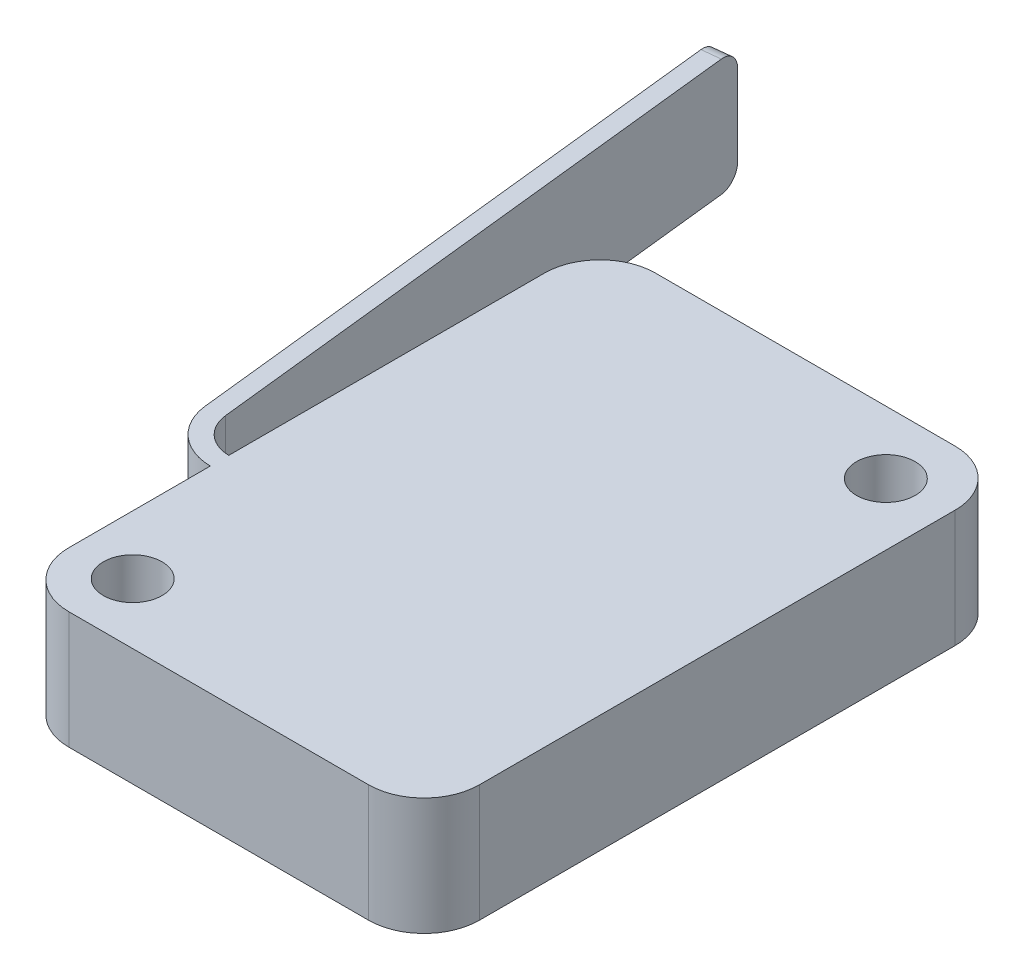
from build123d import *

# Parameters (mm, degrees)
SKETCH1_W           = 22.225
SKETCH1_H           = 31.75
BOSS_EXTRUDE1_DEPTH = 6.35
FILLET1_R           = 3
BOSS_EXTRUDE2_DEPTH = 6.35
FILLET2_R           = 1
SKETCH3_R           = 1.5875
CUT_EXTRUDE1_DEPTH  = 16.35


with BuildPart() as part:
    # Sketch1 → Boss-Extrude1 (new body)
    with BuildSketch(Plane(origin=(0, 0, 0), x_dir=(1, 0, 0), z_dir=(0, 1, 0))):
        Rectangle(SKETCH1_W, SKETCH1_H)
    extrude(amount=BOSS_EXTRUDE1_DEPTH)

    # Fillet1
    fillet1_edges = [part.edges().sort_by_distance(p)[0] for p in [
        (11.1125, 3.175, 15.875),
        (-11.1125, 3.175, 15.875),
        (-11.1125, 3.175, -15.875),
        (11.1125, 3.175, -15.875),
    ]]
    fillet(fillet1_edges, radius=FILLET1_R)

    # Sketch2 → Boss-Extrude2 (add)
    with BuildSketch(Plane(origin=(0, 6.35, 0), x_dir=(1, 0, 0), z_dir=(0, 1, 0))):
        with BuildLine():
            Line((-17.4625, 28.575), (-14.058436423, -2.543223758))
            ThreePointArc((-14.058436423, -2.543223758), (-13.078889385, -4.450679351), (-11.076226608, -5.21699589))
            Line((-11.076226608, -5.21699589), (-6.223943536, -5.21699589))
            Line((-6.223943536, -5.21699589), (-6.223943536, -4.21699589))
            Line((-6.223943536, -4.21699589), (-11.076226608, -4.21699589))
            ThreePointArc((-11.076226608, -4.21699589), (-12.411335126, -3.706118197), (-13.064366485, -2.434481136))
            Line((-13.064366485, -2.434481136), (-16.468430062, 28.683742623))
            Line((-16.468430062, 28.683742623), (-17.4625, 28.575))
        make_face()
    extrude(amount=-BOSS_EXTRUDE2_DEPTH)

    # Fillet2
    fillet2_edges = [part.edges().sort_by_distance(p)[0] for p in [
        (-16.965465031, 6.35, -28.629371311),
        (-16.965465031, 0, -28.629371311),
    ]]
    fillet(fillet2_edges, radius=FILLET2_R)

    # Sketch3 → Cut-Extrude1 (cut)
    with BuildSketch(Plane(origin=(0, 6.35, 0), x_dir=(1, 0, 0), z_dir=(0, 1, 0))):
        with Locations((7.756160145, 12.478354906)):
            Circle(SKETCH3_R)
        with Locations((-7.930929808, -12.598511213)):
            Circle(SKETCH3_R)
    extrude(amount=-CUT_EXTRUDE1_DEPTH, mode=Mode.SUBTRACT)


solid = part.part
